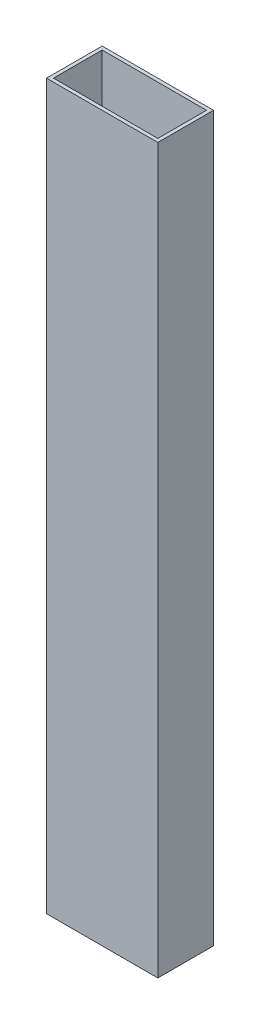
from build123d import *

# Parameters (mm, degrees)
SKETCH1_W           = 50.8
SKETCH1_H           = 25.4
SKETCH1_W_2         = 47.625
SKETCH1_H_2         = 22.225
EXTRUDE_THIN1_DEPTH = 330.2


with BuildPart() as part:
    # Sketch1 → Extrude-Thin1 (new body)
    with BuildSketch(Plane(origin=(0, 0, 0), x_dir=(1, 0, 0), z_dir=(0, 1, 0))):
        with Locations((25.4, 12.7)):
            Rectangle(SKETCH1_W, SKETCH1_H)
        with Locations((25.4, 12.7)):
            Rectangle(SKETCH1_W_2, SKETCH1_H_2, mode=Mode.SUBTRACT)
    extrude(amount=EXTRUDE_THIN1_DEPTH)


solid = part.part
